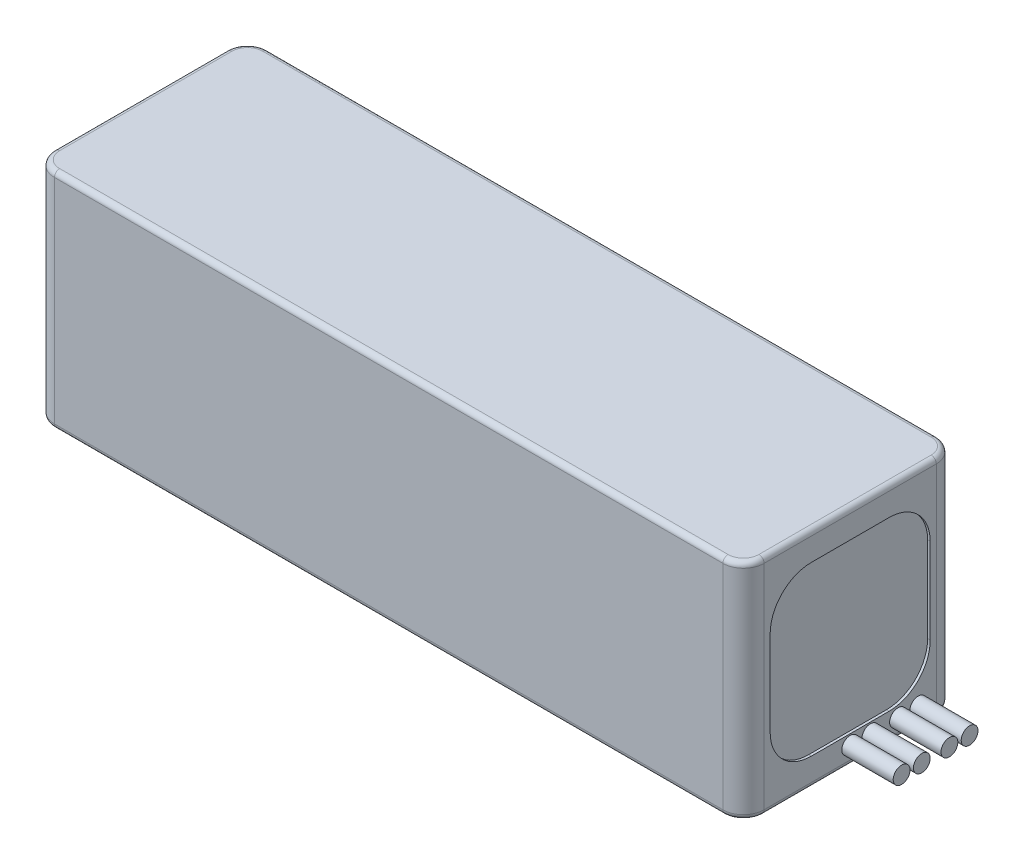
from build123d import *

# Parameters (mm, degrees)
SKETCH1_W           = 138
SKETCH1_H           = 43.5
BOSS_EXTRUDE1_DEPTH = 41.5
CUT_EXTRUDE1_DEPTH  = 0.5
CUT_EXTRUDE2_DEPTH  = 0.5
FILLET1_R           = 4
FILLET2_R           = 1
SKETCH5_R           = 1.635
BOSS_EXTRUDE2_DEPTH = 10


with BuildPart() as part:
    # Sketch1 → Boss-Extrude1 (new body)
    with BuildSketch(Plane(origin=(0, 0, -15), x_dir=(-1, 0, 0), z_dir=(0, 0, -1))):
        with Locations((0, -0.25)):
            Rectangle(SKETCH1_W, SKETCH1_H)
    extrude(amount=-BOSS_EXTRUDE1_DEPTH)

    # Sketch2 → Cut-Extrude1 (cut)
    with BuildSketch(Plane(origin=(69, 0, 0), x_dir=(0, 0, -1), z_dir=(1, 0, 0))):
        with BuildLine():
            Line((-21.3125, 8.0625), (-21.3125, -8.5625))
            ThreePointArc((-21.3125, -8.5625), (-18.969354249, -14.219354249), (-13.3125, -16.5625))
            Line((-13.3125, -16.5625), (1.8125, -16.5625))
            ThreePointArc((1.8125, -16.5625), (7.469354249, -14.219354249), (9.8125, -8.5625))
            Line((9.8125, -8.5625), (9.8125, 8.0625))
            ThreePointArc((9.8125, 8.0625), (7.469354249, 13.719354249), (1.8125, 16.0625))
            Line((1.8125, 16.0625), (-13.3125, 16.0625))
            ThreePointArc((-13.3125, 16.0625), (-18.969354249, 13.719354249), (-21.3125, 8.0625))
        make_face()
    extrude(amount=-CUT_EXTRUDE1_DEPTH, mode=Mode.SUBTRACT)

    # Sketch3 → Cut-Extrude2 (cut)
    with BuildSketch(Plane.ZY.offset(69)):
        with BuildLine():
            Line((13.3125, 16.0625), (-1.8125, 16.0625))
            ThreePointArc((-1.8125, 16.0625), (-7.469354249, 13.719354249), (-9.8125, 8.0625))
            Line((-9.8125, 8.0625), (-9.8125, -8.5625))
            ThreePointArc((-9.8125, -8.5625), (-7.469354249, -14.219354249), (-1.8125, -16.5625))
            Line((-1.8125, -16.5625), (13.3125, -16.5625))
            ThreePointArc((13.3125, -16.5625), (18.969354249, -14.219354249), (21.3125, -8.5625))
            Line((21.3125, -8.5625), (21.3125, 8.0625))
            ThreePointArc((21.3125, 8.0625), (18.969354249, 13.719354249), (13.3125, 16.0625))
        make_face()
    extrude(amount=-CUT_EXTRUDE2_DEPTH, mode=Mode.SUBTRACT)

    # Fillet1
    fillet1_edges = [part.edges().sort_by_distance(p)[0] for p in [
        (-69, -0.25, 26.5),
        (69, -0.25, 26.5),
        (-69, -0.25, -15),
        (69, -0.25, -15),
    ]]
    fillet(fillet1_edges, radius=FILLET1_R)

    # Fillet2
    fillet2_edges = [part.edges().sort_by_distance(p)[0] for p in [
        (0, -22, -15),
        (0, 21.5, -15),
        (-69, 21.5, 5.75),
        (0, 21.5, 26.5),
        (69, 21.5, 5.75),
        (67.828427125, 21.5, 25.328427125),
        (67.828427125, 21.5, -13.828427125),
        (-67.828427125, 21.5, 25.328427125),
        (-67.828427125, 21.5, -13.828427125),
        (-69, -22, 5.75),
        (69, -22, 5.75),
        (0, -22, 26.5),
        (67.828427125, -22, 25.328427125),
        (67.828427125, -22, -13.828427125),
        (-67.828427125, -22, 25.328427125),
        (-67.828427125, -22, -13.828427125),
    ]]
    fillet(fillet2_edges, radius=FILLET2_R)

    # Sketch5 → Boss-Extrude2 (add)
    with BuildSketch(Plane.ZY.offset(-69)):
        with Locations((-7.474307757, -18.480417137)):
            Circle(SKETCH5_R)
        with Locations((-3.551789479, -18.480417137)):
            Circle(SKETCH5_R)
        with Locations((1.821805343, -18.480417137)):
            Circle(SKETCH5_R)
        with Locations((5.75, -18.480417137)):
            Circle(SKETCH5_R)
    extrude(amount=-BOSS_EXTRUDE2_DEPTH)


solid = part.part
